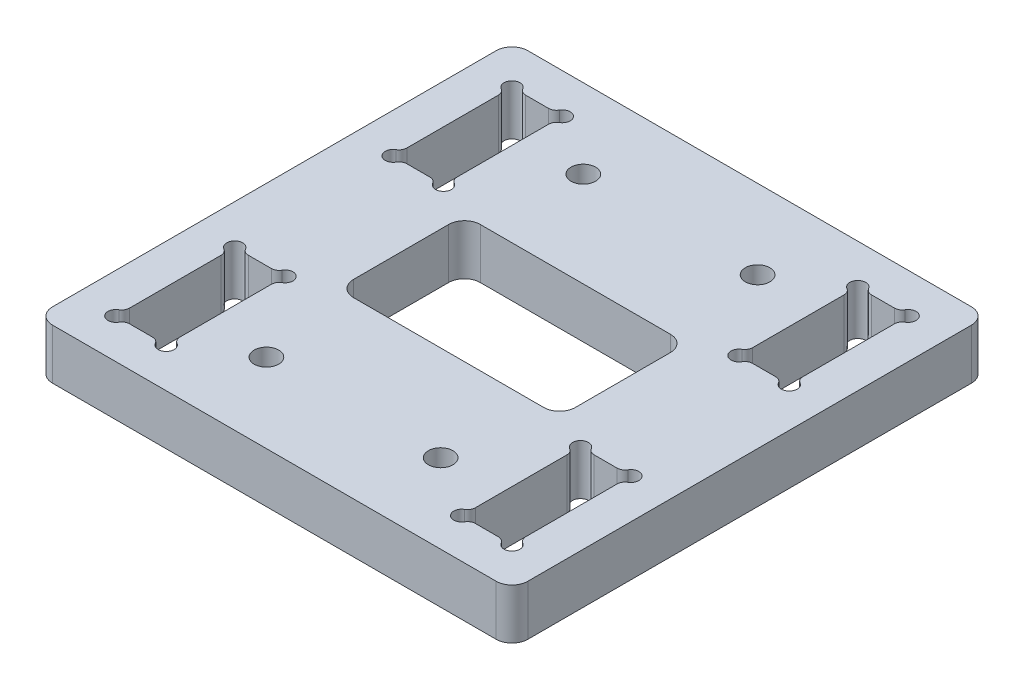
from build123d import *

# Parameters (mm, degrees)
SKETCH1_W                        = 60
SKETCH1_H                        = 60
BOSS_EXTRUDE1_DEPTH              = 6.35
SKETCH2_W                        = 28
SKETCH2_H                        = 16
CUT_EXTRUDE1_DEPTH               = 43.898980174
CBORE_FOR_M2_5_SHCS1_D           = 3.1
CBORE_FOR_M2_5_SHCS1_CBORE_D     = 5.5
CBORE_FOR_M2_5_SHCS1_CBORE_DEPTH = 2.5
MOVE_FACE2_BY                    = 0.15
MOVE_FACE2_2_BY                  = 0.15
MOVE_FACE2_3_BY                  = 0.15
MOVE_FACE2_4_BY                  = 0.15
SKETCH5_W                        = 6.35
SKETCH5_H                        = 15
CUT_EXTRUDE2_DEPTH               = 43.898980174
CUT_EXTRUDE3_DEPTH               = 43.898980174
MIRROR2_COPY_1_DEPTH             = 43.898980174
FILLET1_R                        = 2


with BuildPart() as part:
    # Sketch1 → Boss-Extrude1 (new body)
    with BuildSketch(Plane(origin=(0, 0, 0), x_dir=(1, 0, 0), z_dir=(0, 1, 0))):
        Rectangle(SKETCH1_W, SKETCH1_H)
    extrude(amount=BOSS_EXTRUDE1_DEPTH)

    # Sketch2 → Cut-Extrude1 (cut, through all)
    with BuildSketch(Plane(origin=(0, 6.35, 0), x_dir=(1, 0, 0), z_dir=(0, 1, 0))):
        Rectangle(SKETCH2_W, SKETCH2_H)
    extrude(amount=-CUT_EXTRUDE1_DEPTH, mode=Mode.SUBTRACT)

    # CBORE for M2.5 SHCS1 (through all)
    with Locations(Plane(origin=(0, 0, 0), x_dir=(-1, 0, 0), z_dir=(0, -1, 0))):
        with Locations((-11, 20), (11, 20), (-11, -20), (11, -20)):
            CounterBoreHole(CBORE_FOR_M2_5_SHCS1_D / 2, CBORE_FOR_M2_5_SHCS1_CBORE_D / 2, CBORE_FOR_M2_5_SHCS1_CBORE_DEPTH)

    # Move Face2: a face moved outward by 0.15
    extrude(part.faces().sort_by_distance((11, 2.5, -17.8))[0], amount=MOVE_FACE2_BY, dir=(0, -1, 0))

    # Move Face2 2: a face moved outward by 0.15
    extrude(part.faces().sort_by_distance((11, 2.5, 22.2))[0], amount=MOVE_FACE2_2_BY, dir=(0, -1, 0))

    # Move Face2 3: a face moved outward by 0.15
    extrude(part.faces().sort_by_distance((-11, 2.5, 22.2))[0], amount=MOVE_FACE2_3_BY, dir=(0, -1, 0))

    # Move Face2 4: a face moved outward by 0.15
    extrude(part.faces().sort_by_distance((-11, 2.5, -17.8))[0], amount=MOVE_FACE2_4_BY, dir=(0, -1, 0))

    # Sketch5 → Cut-Extrude2 (cut, through all)
    with BuildSketch(Plane(origin=(0, 6.35, 0), x_dir=(1, 0, 0), z_dir=(0, 1, 0))):
        with Locations((21.825, 17.5)):
            Rectangle(SKETCH5_W, SKETCH5_H)
    extrude(amount=-CUT_EXTRUDE2_DEPTH, mode=Mode.SUBTRACT)

    # Sketch6 → Cut-Extrude3 (cut, through all)
    with BuildSketch(Plane(origin=(0, 6.35, 0), x_dir=(1, 0, 0), z_dir=(0, 1, 0))):
        with BuildLine():
            Line((23.267949192, 25), (20.382050808, 25))
            ThreePointArc((20.382050808, 25), (19.882050808, 25.133974596), (19.516025404, 25.5))
            ThreePointArc((19.516025404, 25.5), (17.942893219, 25.707106781), (18.15, 24.133974596))
            ThreePointArc((18.15, 24.133974596), (18.516025404, 23.767949192), (18.65, 23.267949192))
            Line((18.65, 23.267949192), (18.65, 11.732050808))
            ThreePointArc((18.65, 11.732050808), (18.516025404, 11.232050808), (18.15, 10.866025404))
            ThreePointArc((18.15, 10.866025404), (17.942893219, 9.292893219), (19.516025404, 9.5))
            ThreePointArc((19.516025404, 9.5), (19.882050808, 9.866025404), (20.382050808, 10))
            Line((20.382050808, 10), (23.267949192, 10))
            ThreePointArc((23.267949192, 10), (23.767949192, 9.866025404), (24.133974596, 9.5))
            ThreePointArc((24.133974596, 9.5), (25.707106781, 9.292893219), (25.5, 10.866025404))
            ThreePointArc((25.5, 10.866025404), (25.133974596, 11.232050808), (25, 11.732050808))
            Line((25, 11.732050808), (25, 23.267949192))
            ThreePointArc((25, 23.267949192), (25.133974596, 23.767949192), (25.5, 24.133974596))
            ThreePointArc((25.5, 24.133974596), (25.707106781, 25.707106781), (24.133974596, 25.5))
            ThreePointArc((24.133974596, 25.5), (23.767949192, 25.133974596), (23.267949192, 25))
        make_face()
    cut_extrude3 = extrude(amount=-CUT_EXTRUDE3_DEPTH, mode=Mode.SUBTRACT)

    # Mirror1: Cut-Extrude3 across plane
    add(cut_extrude3.mirror(Plane.XY), mode=Mode.SUBTRACT)

    # Mirror2: Cut-Extrude3 across plane
    add(cut_extrude3.mirror(Plane(origin=(0, 0, 0), x_dir=(0, 0, 1), z_dir=(1, 0, 0))), mode=Mode.SUBTRACT)

    # Mirror2 copy 1 sketch → Mirror2 copy 1 (cut, through all)
    with BuildSketch(Plane(origin=(0, 6.35, 0), x_dir=(-1, 0, 0), z_dir=(0, 1, 0))):
        with BuildLine():
            Line((23.267949192, 25), (20.382050808, 25))
            ThreePointArc((20.382050808, 25), (19.882050808, 25.133974596), (19.516025404, 25.5))
            ThreePointArc((19.516025404, 25.5), (17.942893219, 25.707106781), (18.15, 24.133974596))
            ThreePointArc((18.15, 24.133974596), (18.516025404, 23.767949192), (18.65, 23.267949192))
            Line((18.65, 23.267949192), (18.65, 11.732050808))
            ThreePointArc((18.65, 11.732050808), (18.516025404, 11.232050808), (18.15, 10.866025404))
            ThreePointArc((18.15, 10.866025404), (17.942893219, 9.292893219), (19.516025404, 9.5))
            ThreePointArc((19.516025404, 9.5), (19.882050808, 9.866025404), (20.382050808, 10))
            Line((20.382050808, 10), (23.267949192, 10))
            ThreePointArc((23.267949192, 10), (23.767949192, 9.866025404), (24.133974596, 9.5))
            ThreePointArc((24.133974596, 9.5), (25.707106781, 9.292893219), (25.5, 10.866025404))
            ThreePointArc((25.5, 10.866025404), (25.133974596, 11.232050808), (25, 11.732050808))
            Line((25, 11.732050808), (25, 23.267949192))
            ThreePointArc((25, 23.267949192), (25.133974596, 23.767949192), (25.5, 24.133974596))
            ThreePointArc((25.5, 24.133974596), (25.707106781, 25.707106781), (24.133974596, 25.5))
            ThreePointArc((24.133974596, 25.5), (23.767949192, 25.133974596), (23.267949192, 25))
        make_face()
    extrude(amount=-MIRROR2_COPY_1_DEPTH, mode=Mode.SUBTRACT)

    # Fillet1
    fillet1_edges = [part.edges().sort_by_distance(p)[0] for p in [
        (-14, 3.175, 8),
        (-14, 3.175, -8),
        (14, 3.175, -8),
        (14, 3.175, 8),
        (-30, 3.175, -30),
        (30, 3.175, -30),
        (30, 3.175, 30),
        (-30, 3.175, 30),
    ]]
    fillet(fillet1_edges, radius=FILLET1_R)


solid = part.part
